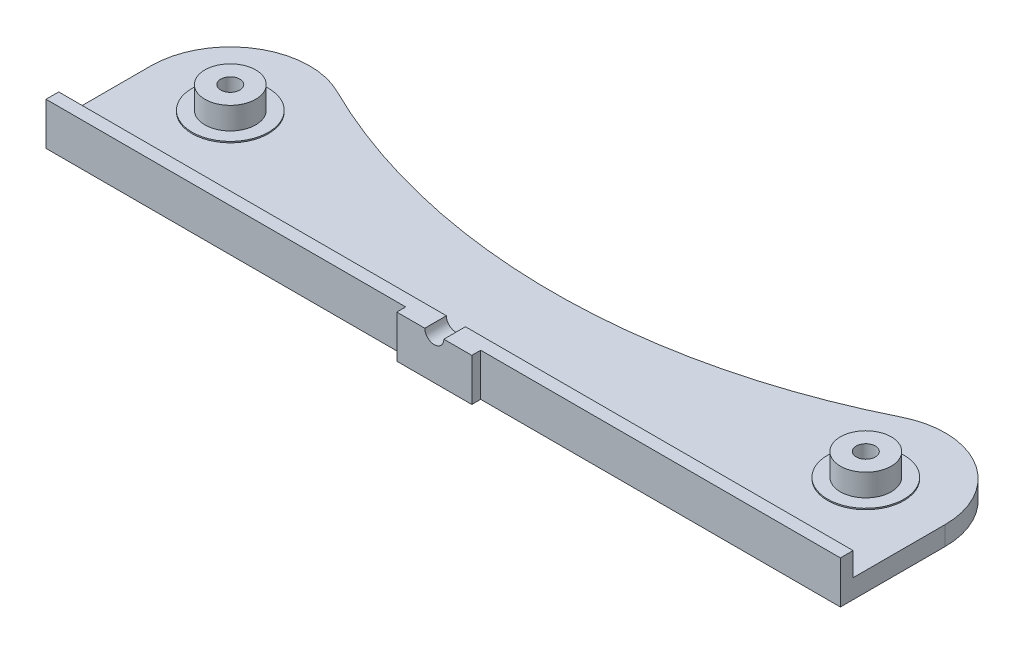
from build123d import *

# Parameters (mm, degrees)
SKETCH1_R           = 1.5
BOSS_EXTRUDE1_DEPTH = 3
BOSS_EXTRUDE2_START = 3
SKETCH1_3_W         = 11.8
SKETCH1_3_H         = 1.4
SKETCH1_3_W_2       = 125
SKETCH1_3_H_2       = 2
BOSS_EXTRUDE2_DEPTH = 3.7
SKETCH2_R           = 1.5
CUT_EXTRUDE1_DEPTH  = 69.411548733
SKETCH3_R           = 6
SKETCH3_R_2         = 1.5
BOSS_EXTRUDE3_DEPTH = 0.2


with BuildPart() as part:
    # Sketch1 → Boss-Extrude1 (new body)
    with BuildSketch(Plane(origin=(0, 0, 0), x_dir=(1, 0, 0), z_dir=(0, 1, 0))):
        with BuildLine():
            Line((-62.5, 0), (-5.9, 0))
            Line((-5.9, 0), (-5.9, -1.4))
            Line((-5.9, -1.4), (5.9, -1.4))
            Line((5.9, -1.4), (5.9, 0))
            Line((5.9, 0), (62.5, 0))
            Line((62.5, 0), (62.5, 16.5))
            ThreePointArc((62.5, 16.5), (56.588078143, 27.122957516), (44.444443779, 27.697579876))
            ThreePointArc((44.444443779, 27.697579876), (-1.61e-07, 17.278221854), (-44.444444068, 27.697580019))
            ThreePointArc((-44.444444068, 27.697580019), (-56.58807828, 27.122957431), (-62.5, 16.5))
            Line((-62.5, 16.5), (-62.5, 0))
        make_face()
        with Locations(Location((50, 16.5, 0), (0, 0, 270))):
            Circle(SKETCH1_R, mode=Mode.SUBTRACT)
        with Locations(Location((-50, 16.5, 0), (0, 0, 270))):
            Circle(SKETCH1_R, mode=Mode.SUBTRACT)
    extrude(amount=BOSS_EXTRUDE1_DEPTH)

    # Sketch1_3 → Boss-Extrude2 (add)
    with BuildSketch(Plane(origin=(0, 0, 0), x_dir=(1, 0, 0), z_dir=(0, 1, 0)).offset(BOSS_EXTRUDE2_START)):
        with BuildLine():
            ThreePointArc((-46, 16.5), (-50, 20.5), (-54, 16.5))
            Line((-54, 16.5), (-51.5, 16.5))
            ThreePointArc((-51.5, 16.5), (-50, 18), (-48.5, 16.5))
            Line((-48.5, 16.5), (-46, 16.5))
        make_face()
        with BuildLine():
            Line((-51.5, 16.5), (-54, 16.5))
            ThreePointArc((-54, 16.5), (-50, 12.5), (-46, 16.5))
            Line((-46, 16.5), (-48.5, 16.5))
            ThreePointArc((-48.5, 16.5), (-50, 15), (-51.5, 16.5))
        make_face()
        with BuildLine():
            ThreePointArc((46, 16.5), (50, 12.5), (54, 16.5))
            Line((54, 16.5), (51.5, 16.5))
            ThreePointArc((51.5, 16.5), (50, 15), (48.5, 16.5))
            Line((48.5, 16.5), (46, 16.5))
        make_face()
        with BuildLine():
            Line((51.5, 16.5), (54, 16.5))
            ThreePointArc((54, 16.5), (50, 20.5), (46, 16.5))
            Line((46, 16.5), (48.5, 16.5))
            ThreePointArc((48.5, 16.5), (50, 18), (51.5, 16.5))
        make_face()
        with Locations((0, -0.7)):
            Rectangle(SKETCH1_3_W, SKETCH1_3_H)
        with Locations((0, 1)):
            Rectangle(SKETCH1_3_W_2, SKETCH1_3_H_2)
    extrude(amount=BOSS_EXTRUDE2_DEPTH)

    # Sketch2 → Cut-Extrude1 (cut, through all)
    with BuildSketch(Plane(origin=(0, 0, -2), x_dir=(-1, 0, 0), z_dir=(0, 0, -1))):
        with Locations((0, 6.7)):
            Circle(SKETCH2_R)
    extrude(amount=-CUT_EXTRUDE1_DEPTH, mode=Mode.SUBTRACT)

    # Sketch3 → Boss-Extrude3 (add)
    with BuildSketch(Plane(origin=(0, 3, 0), x_dir=(1, 0, 0), z_dir=(0, 1, 0))):
        with Locations(Location((-50, 16.5, 0), (0, 0, 270))):
            Circle(SKETCH3_R)
        with Locations(Location((-50, 16.5, 0), (0, 0, 270))):
            Circle(SKETCH3_R_2, mode=Mode.SUBTRACT)
        with Locations(Location((50, 16.5, 0), (0, 0, 270))):
            Circle(SKETCH3_R)
        with Locations(Location((50, 16.5, 0), (0, 0, 270))):
            Circle(SKETCH3_R_2, mode=Mode.SUBTRACT)
    extrude(amount=BOSS_EXTRUDE3_DEPTH)


solid = part.part
